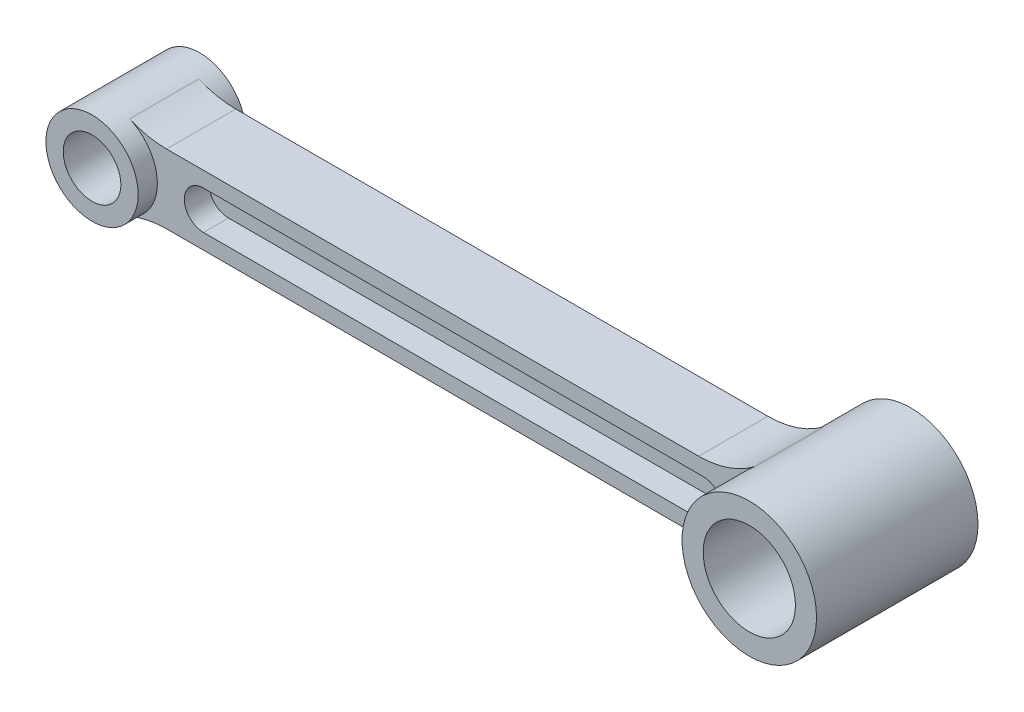
from build123d import *

# Parameters (mm, degrees)
SKETCH1_R           = 7.5
BOSS_EXTRUDE1_DEPTH = 14
SKETCH1_3_R         = 12
BOSS_EXTRUDE2_DEPTH = 21
BOSS_EXTRUDE3_DEPTH = 9
BOSS_EXTRUDE4_DEPTH = 2.5


with BuildPart() as part:
    # Sketch1 → Boss-Extrude1 (new, symmetric)
    with BuildSketch(Plane.XY):
        with BuildLine():
            ThreePointArc((-77, 0), (-78.96132533, 6.574573055), (-84.204168477, 11))
            ThreePointArc((-84.204168477, 11), (-101, 0), (-84.204168477, -11))
            ThreePointArc((-84.204168477, -11), (-78.96132533, -6.574573055), (-77, 0))
        make_face()
        with Locations((-89, 0)):
            Circle(SKETCH1_R, mode=Mode.SUBTRACT)
    extrude(amount=BOSS_EXTRUDE1_DEPTH, both=True)



with BuildPart() as body_2:
    # Sketch1_3 → Boss-Extrude2 (new, symmetric)
    with BuildSketch(Plane.XY):
        with BuildLine():
            ThreePointArc((106.5, 0), (96.76364668, 15.683615343), (78.388481117, 13.915662651))
            ThreePointArc((78.388481117, 13.915662651), (71.5, 0), (78.388481117, -13.915662651))
            ThreePointArc((78.388481117, -13.915662651), (96.76364668, -15.683615343), (106.5, 0))
        make_face()
        with Locations((89, 0)):
            Circle(SKETCH1_3_R, mode=Mode.SUBTRACT)
    extrude(amount=BOSS_EXTRUDE2_DEPTH, both=True)


with BuildPart() as part_1:
    add(part.part)

    add(body_2.part)  # Boss-Extrude3 merges body 2
    # Sketch1_4 → Boss-Extrude3 (add, symmetric)
    with BuildSketch(Plane.XY):
        with BuildLine():
            Line((63.835540936, 9), (-74.61250543, 9))
            ThreePointArc((-74.61250543, 9), (-79.511484916, 9.505319751), (-84.204168477, 11))
            ThreePointArc((-84.204168477, 11), (-78.96132533, 6.574573055), (-77, 0))
            ThreePointArc((-77, 0), (-78.96132533, -6.574573055), (-84.204168477, -11))
            ThreePointArc((-84.204168477, -11), (-79.511484916, -9.505319751), (-74.61250543, -9))
            Line((-74.61250543, -9), (63.835540936, -9))
            ThreePointArc((63.835540936, -9), (71.515902373, -10.26210106), (78.388481117, -13.915662651))
            ThreePointArc((78.388481117, -13.915662651), (71.5, 0), (78.388481117, 13.915662651))
            ThreePointArc((78.388481117, 13.915662651), (71.515902373, 10.26210106), (63.835540936, 9))
        make_face()
        with BuildLine():
            ThreePointArc((65, 5), (70, 0), (65, -5))
            Line((65, -5), (-65, -5))
            ThreePointArc((-65, -5), (-70, 0), (-65, 5))
            Line((-65, 5), (65, 5))
        make_face(mode=Mode.SUBTRACT)
    extrude(amount=BOSS_EXTRUDE3_DEPTH, both=True)

    # Sketch1_5 → Boss-Extrude4 (add, symmetric)
    with BuildSketch(Plane.XY):
        with BuildLine():
            Line((-65, -5), (65, -5))
            ThreePointArc((65, -5), (70, 0), (65, 5))
            Line((65, 5), (-65, 5))
            ThreePointArc((-65, 5), (-70, 0), (-65, -5))
        make_face()
    extrude(amount=BOSS_EXTRUDE4_DEPTH, both=True)


solid = part_1.part
